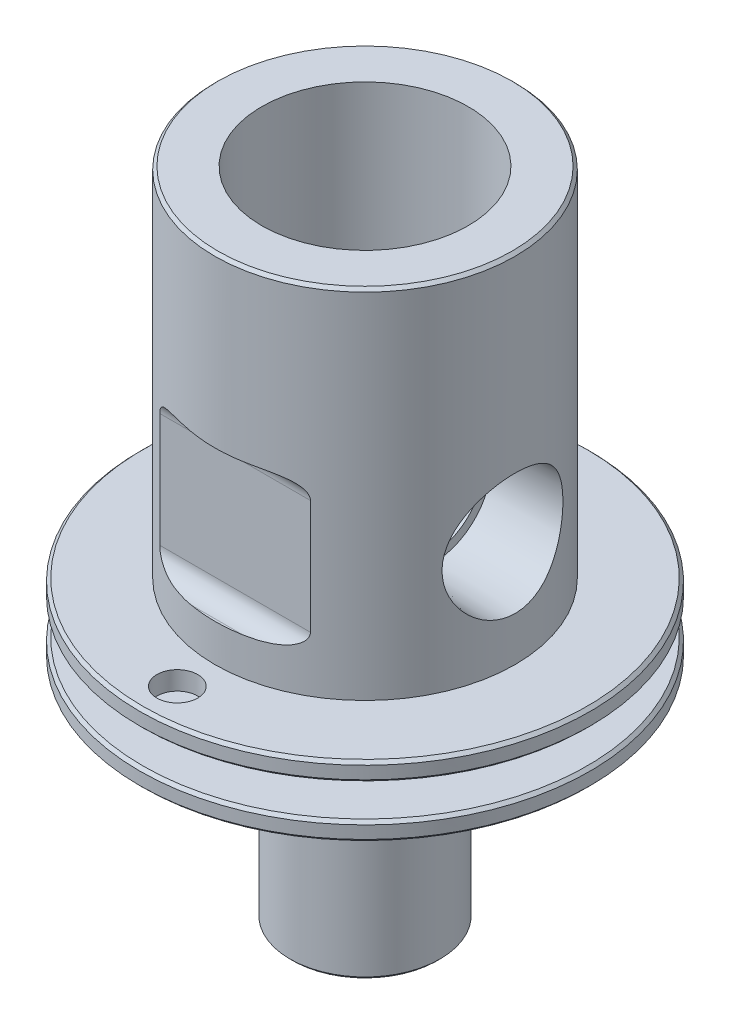
from build123d import *

# Parameters (mm, degrees)
F_3_4_16_TAPPED_HOLE1_D     = 17.4625
F_3_4_16_TAPPED_HOLE1_DEPTH = 12.5222
F_3_4_16_TAPPED_HOLE1_TIP   = 8.73125
SKETCH9_R                   = 4.7625
THRU_HOLE_DEPTH             = 62.384040094
WRENCH_FLATS_7_8_DEPTH      = 12.7
BREAK_ALL_EDGES_SIZE        = 0.254
F_8_32_TAPPED_HOLE1_D       = 3.4544
F_8_32_TAPPED_HOLE1_DEPTH   = 4.3688


with BuildPart() as part:
    # Sketch1 → Revolve1 (revolve)
    with BuildSketch(Plane(origin=(0, 0, 0), x_dir=(0, 0, -1), z_dir=(1, 0, 0))):
        Polygon((0, 0), (-12.7, 0), (-12.7, -30.1625), (-19.05, -30.1625), (-19.05, -31.7373), (-6.35, -31.7373), (-6.35, -34.5313), (-19.05, -34.5313), (-19.05, -36.1061), (-6.35, -36.1061), (-6.35, -55.1561), (0, -55.1561), align=None)
    revolve(axis=Axis((0, 0, 0), (0, -1, 0)))

    # Sketch5 → 1/8 NPT Tapped Hole1 (revolve, cut)
    with BuildSketch(Plane(origin=(12.7, -21.2725, 0), x_dir=(0, 0, -1), z_dir=(0, 1, 0))):
        Polygon((0, 0), (0, 14.166668714), (4.2164, 11.6332), (4.2164, 6.9342), (4.936185566, 6.9342), (5.1438048, 0), align=None)
    revolve(axis=Axis((19.05, -21.2725, 0), (-1, 0, 0)), mode=Mode.SUBTRACT)

    # 3/4-16 Tapped Hole1
    with Locations(Plane(origin=(0, 0, 0), x_dir=(-1, 0, 0), z_dir=(0, 1, 0))):
        with Locations((0, 0)):
            Hole(F_3_4_16_TAPPED_HOLE1_D / 2, depth=F_3_4_16_TAPPED_HOLE1_DEPTH)
            with Locations((0, 0, -(F_3_4_16_TAPPED_HOLE1_DEPTH + F_3_4_16_TAPPED_HOLE1_TIP / 2))):  # 90° drill point
                Cone(0, F_3_4_16_TAPPED_HOLE1_D / 2, F_3_4_16_TAPPED_HOLE1_TIP, mode=Mode.SUBTRACT)

    # Sketch9 → Thru hole (cut, through all)
    with BuildSketch(Plane.XZ.offset(55.1561)):
        with Locations(Location((0, 0, 0), (0, 0, 270))):
            Circle(SKETCH9_R)
    extrude(amount=-THRU_HOLE_DEPTH, mode=Mode.SUBTRACT)

    # Sketch10 → Wrench flats 7/8" (cut, symmetric)
    with BuildSketch(Plane(origin=(0, 0, 0), x_dir=(0, 0, -1), z_dir=(1, 0, 0))):
        with BuildLine():
            Line((-12.7, -14.2875), (-12.5095, -14.2875))
            ThreePointArc((-12.5095, -14.2875), (-11.431869265, -14.733869265), (-10.9855, -15.8115))
            Line((-10.9855, -15.8115), (-10.9855, -25.4635))
            ThreePointArc((-10.9855, -25.4635), (-11.431869265, -26.541130735), (-12.5095, -26.9875))
            Line((-12.5095, -26.9875), (-12.7, -26.9875))
            Line((-12.7, -26.9875), (-12.7, -14.2875))
        make_face()
        with BuildLine():
            Line((10.9855, -15.8115), (10.9855, -25.4635))
            ThreePointArc((10.9855, -25.4635), (11.431869265, -26.541130735), (12.5095, -26.9875))
            Line((12.5095, -26.9875), (12.7, -26.9875))
            Line((12.7, -26.9875), (12.7, -14.2875))
            Line((12.7, -14.2875), (12.5095, -14.2875))
            ThreePointArc((12.5095, -14.2875), (11.431869265, -14.733869265), (10.9855, -15.8115))
        make_face()
    extrude(amount=WRENCH_FLATS_7_8_DEPTH, both=True, mode=Mode.SUBTRACT)

    # Break all edges
    break_all_edges_edges = [part.edges().sort_by_distance(p)[0] for p in [
        (0, -34.5313, -19.05),
        (0, -36.1061, -19.05),
        (0, -55.1561, -6.35),
        (0, -55.1561, 4.7625),
        (0, 0, -12.7),
        (0, -30.1625, -19.05),
        (0, -31.7373, -19.05),
    ]]
    chamfer(break_all_edges_edges, length=BREAK_ALL_EDGES_SIZE)

    # #8-32 Tapped Hole1
    with Locations(Plane(origin=(0, -30.1625, 0), x_dir=(-1, 0, 0), z_dir=(0, 1, 0))):
        with Locations((0, 15.875)):
            Hole(F_8_32_TAPPED_HOLE1_D / 2, depth=F_8_32_TAPPED_HOLE1_DEPTH)


solid = part.part
